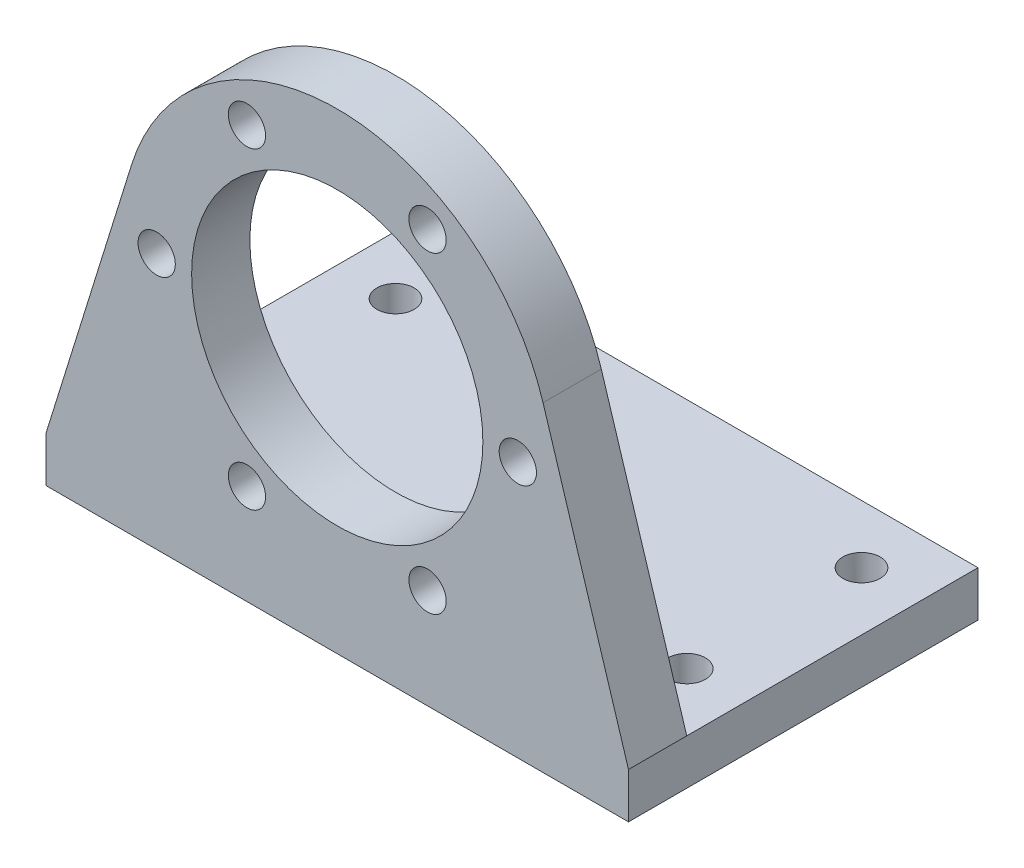
from build123d import *

# Parameters (mm, degrees)
SKETCH_1_R          = 1.6
SKETCH_1_R_2        = 12.5
EXTRUDE_1_DEPTH     = 5
SKETCH_2_W          = 50
SKETCH_2_H          = 3.896696611
EXTRUDE_2_DEPTH     = 25
SKETCH_3_R          = 1.6
CUT_EXTRUDE_1_DEPTH = 25


with BuildPart() as part:
    # 草图1 → 凸台-拉伸1 (new body)
    with BuildSketch(Plane.XY):
        with BuildLine():
            Line((-25, -22), (25, -22))
            Line((25, -22), (25, -18.103303389))
            Line((25, -18.103303389), (17.666287953, 5.491108263))
            ThreePointArc((17.666287953, 5.491108263), (0, 18.5), (-17.666287953, 5.491108263))
            Line((-17.666287953, 5.491108263), (-25, -18.103303389))
            Line((-25, -18.103303389), (-25, -22))
        make_face()
        with Locations((-15.5, 0)):
            Circle(SKETCH_1_R, mode=Mode.SUBTRACT)
        with Locations((-7.75, 13.423393759)):
            Circle(SKETCH_1_R, mode=Mode.SUBTRACT)
        with Locations((7.75, 13.423393759)):
            Circle(SKETCH_1_R, mode=Mode.SUBTRACT)
        with Locations((15.5, 0)):
            Circle(SKETCH_1_R, mode=Mode.SUBTRACT)
        with Locations((7.75, -13.423393759)):
            Circle(SKETCH_1_R, mode=Mode.SUBTRACT)
        with Locations((-7.75, -13.423393759)):
            Circle(SKETCH_1_R, mode=Mode.SUBTRACT)
        Circle(SKETCH_1_R_2, mode=Mode.SUBTRACT)
    extrude(amount=EXTRUDE_1_DEPTH)

    # 草图2 → 凸台-拉伸2 (add)
    with BuildSketch(Plane(origin=(0, 0, 0), x_dir=(-1, 0, 0), z_dir=(0, 0, -1))):
        with Locations((0, -20.051651695)):
            Rectangle(SKETCH_2_W, SKETCH_2_H)
    extrude(amount=EXTRUDE_2_DEPTH)

    # 草图3 → 切除-拉伸1 (cut)
    with BuildSketch(Plane(origin=(0, -18.103303389, 0), x_dir=(1, 0, 0), z_dir=(0, 1, 0))):
        with Locations((-20, 20)):
            Circle(SKETCH_3_R)
        with Locations((20, 20)):
            Circle(SKETCH_3_R)
        with Locations((20, 5)):
            Circle(SKETCH_3_R)
        with Locations((-20, 5)):
            Circle(SKETCH_3_R)
    extrude(amount=-CUT_EXTRUDE_1_DEPTH, mode=Mode.SUBTRACT)


solid = part.part
